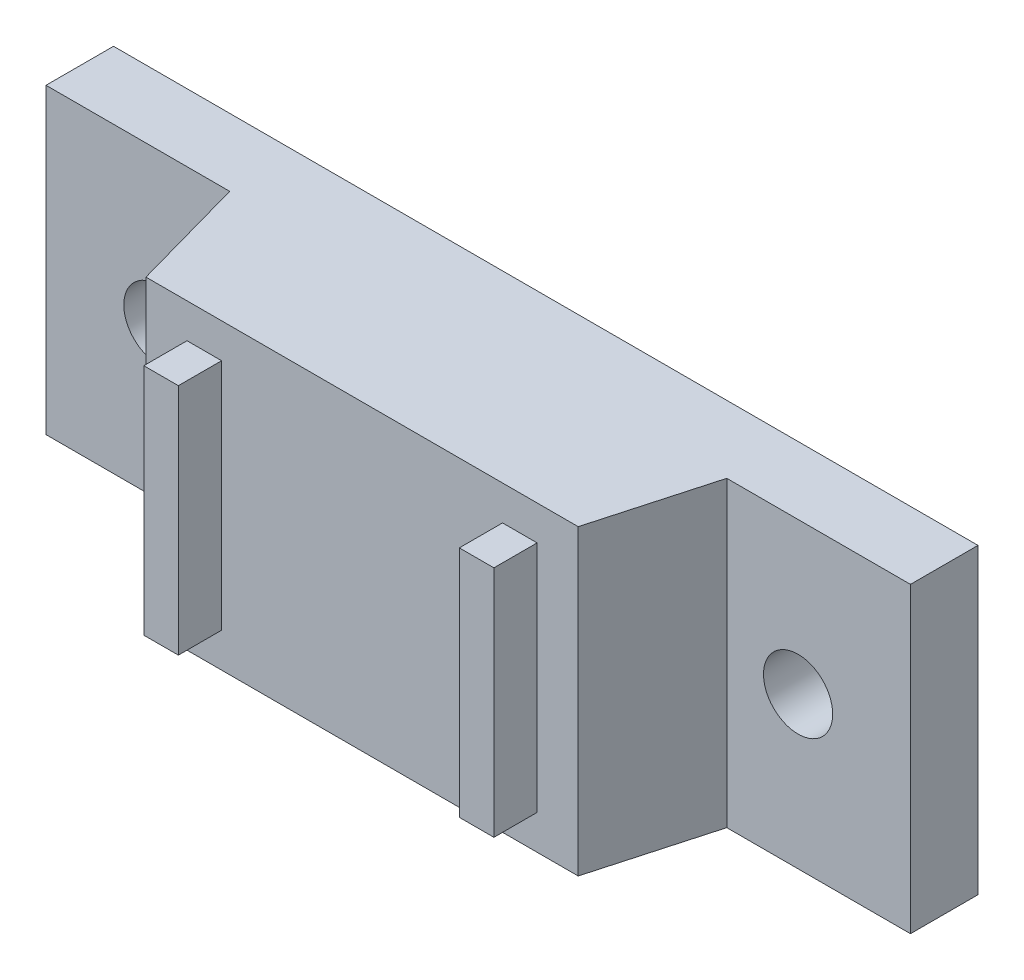
from build123d import *

# Parameters (mm, degrees)
SKETCH1_W             = 17.78
SKETCH1_H             = 50.8
SKETCH1_R             = 2.032
BOSS_EXTRUDE1_DEPTH   = 3.96875
SKETCH3_W             = 17.78
SKETCH3_H             = 25.4
SKETCH2_W             = 17.78
SKETCH2_H             = 29.21
SKETCH4_W             = 13.716
SKETCH4_H             = 2.032
BOSS_EXTRUDE2_DEPTH   = 2.54
EXTRUDE_THIN1_DEPTH   = 14.2875
FILLET1_R             = 2.54
CUT_EXTRUDE1_DEPTH    = 0.9525
SKETCH8_R             = 1.27
CUT_EXTRUDE2_DEPTH    = 0.9525
BODY_MOVE_COPY3_ANGLE = 90


with BuildPart() as part:
    # Sketch1 → Boss-Extrude1 (new body)
    with BuildSketch(Plane.XY):
        Rectangle(SKETCH1_W, SKETCH1_H)
        with Locations((0, 18.796)):
            Circle(SKETCH1_R, mode=Mode.SUBTRACT)
        with Locations((0, -18.796)):
            Circle(SKETCH1_R, mode=Mode.SUBTRACT)
    extrude(amount=BOSS_EXTRUDE1_DEPTH)

    # Sketch3 → Loft1 section 0
    with BuildSketch(Plane.XY.offset(10.795)):
        Rectangle(SKETCH3_W, SKETCH3_H)
    # Sketch2 → Loft1 section 1
    with BuildSketch(Plane.XY.offset(3.96875)):
        Rectangle(SKETCH2_W, SKETCH2_H)
    loft()

    # Sketch4 → Boss-Extrude2 (add)
    with BuildSketch(Plane.XY.offset(10.795)):
        with Locations((0, 9.271)):
            Rectangle(SKETCH4_W, SKETCH4_H)
        with Locations((0, -9.271)):
            Rectangle(SKETCH4_W, SKETCH4_H)
    extrude(amount=BOSS_EXTRUDE2_DEPTH)


with BuildPart() as body_2:
    # Sketch6 → Extrude-Thin1 (new body, symmetric)
    with BuildSketch(Plane(origin=(0, 0, 0), x_dir=(1, 0, 0), z_dir=(0, 1, 0))):
        with BuildLine():
            Line((9.525, -13.335), (-6.985, -13.335))
            ThreePointArc((-6.985, -13.335), (-8.781051224, -14.078948776), (-9.525, -15.875))
            Line((-9.525, -15.875), (-9.525, -31.877))
            Line((-9.525, -31.877), (-8.5725, -31.877))
            Line((-8.5725, -31.877), (-8.5725, -15.875))
            ThreePointArc((-8.5725, -15.875), (-8.107532015, -14.752467985), (-6.985, -14.2875))
            Line((-6.985, -14.2875), (9.525, -14.2875))
            Line((9.525, -14.2875), (9.525, -13.335))
        make_face()
    extrude(amount=EXTRUDE_THIN1_DEPTH, both=True)

    # Fillet1
    fillet1_edges = [body_2.edges().sort_by_distance(p)[0] for p in [
        (9.525, 14.2875, 13.81125),
        (-9.04875, 14.2875, 31.877),
        (9.525, -14.2875, 13.81125),
        (-9.04875, -14.2875, 31.877),
    ]]
    fillet(fillet1_edges, radius=FILLET1_R)

    # Sketch7 → Cut-Extrude1 (cut)
    with BuildSketch(Plane.ZY.offset(9.525)):
        with BuildLine():
            Line((19.304, 11.303), (25.273, 11.303))
            ThreePointArc((25.273, 11.303), (27.051, 9.525), (25.273, 7.747))
            Line((25.273, 7.747), (19.304, 7.747))
            ThreePointArc((19.304, 7.747), (17.526, 9.525), (19.304, 11.303))
        make_face()
        with BuildLine():
            Line((19.304, -7.747), (25.273, -7.747))
            ThreePointArc((25.273, -7.747), (27.051, -9.525), (25.273, -11.303))
            Line((25.273, -11.303), (19.304, -11.303))
            ThreePointArc((19.304, -11.303), (17.526, -9.525), (19.304, -7.747))
        make_face()
    extrude(amount=-CUT_EXTRUDE1_DEPTH, mode=Mode.SUBTRACT)

    # Sketch8 → Cut-Extrude2 (cut)
    with BuildSketch(Plane(origin=(-8.5725, 0, 0), x_dir=(0, 0, -1), z_dir=(1, 0, 0))):
        with Locations((-29.083, 0)):
            Circle(SKETCH8_R)
    extrude(amount=-CUT_EXTRUDE2_DEPTH, mode=Mode.SUBTRACT)


with BuildPart() as body_2_1:
    # Body-Move/Copy1: moved
    add(body_2.part.moved(Location((0, 0, 25.4))))


with BuildPart() as part_1:
    # Body-Move/Copy3: moved
    add(part.part.rotate(Axis((0, 0, 0), (0, 0, 1)), BODY_MOVE_COPY3_ANGLE))


solid = part_1.part
